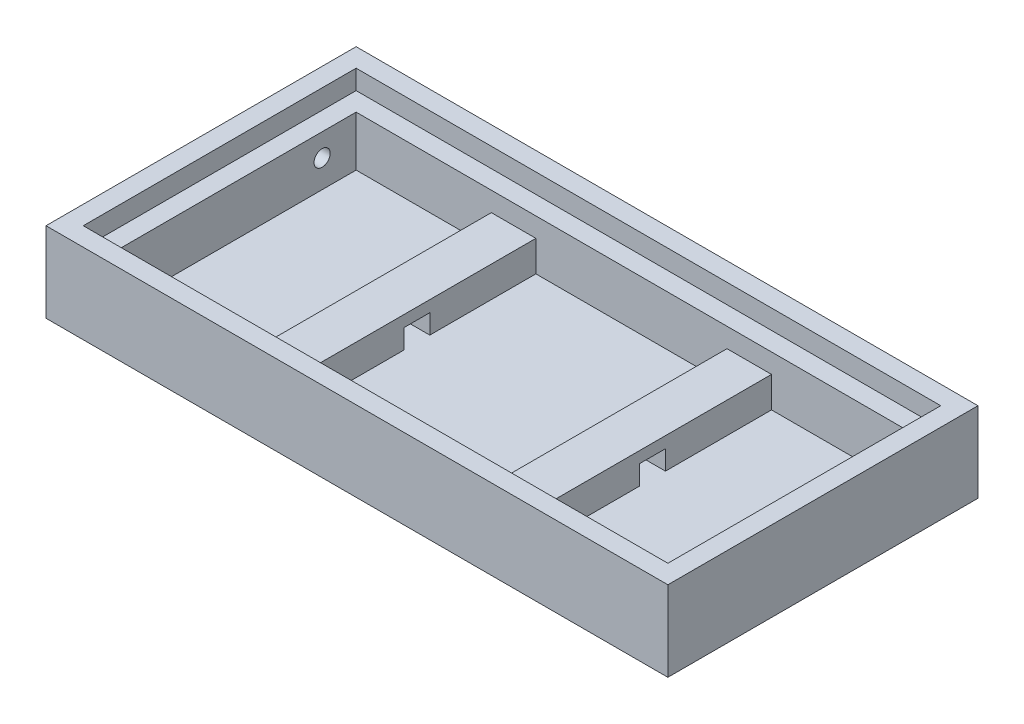
from build123d import *

# Parameters (mm, degrees)
SKETCH3_W           = 1219.2
SKETCH3_H           = 608.0125
BOSS_EXTRUDE1_DEPTH = 20.6375
SKETCH4_W           = 1219.2
SKETCH4_H           = 608.0125
SKETCH4_W_2         = 1146.175
SKETCH4_H_2         = 534.9875
BOSS_EXTRUDE2_DEPTH = 136.525
SKETCH5_W           = 1146.175
SKETCH5_H           = 534.9875
SKETCH5_W_2         = 1073.15
SKETCH5_H_2         = 461.9625
BOSS_EXTRUDE3_DEPTH = 98.425
SKETCH6_W           = 87.3125
SKETCH6_H           = 461.9625
BOSS_EXTRUDE4_DEPTH = 60.325
SKETCH7_W           = 50.8
SKETCH7_H           = 38.1
CUT_EXTRUDE1_DEPTH  = 549.275
SKETCH8_R           = 15.875
CUT_EXTRUDE2_DEPTH  = 73.025


with BuildPart() as part:
    # Sketch3 → Boss-Extrude1 (new body)
    with BuildSketch(Plane(origin=(0, 0, 0), x_dir=(1, 0, 0), z_dir=(0, 1, 0))):
        with Locations((609.6, 304.00625)):
            Rectangle(SKETCH3_W, SKETCH3_H)
    extrude(amount=BOSS_EXTRUDE1_DEPTH)

    # Sketch4 → Boss-Extrude2 (add)
    with BuildSketch(Plane(origin=(0, 20.6375, 0), x_dir=(1, 0, 0), z_dir=(0, 1, 0))):
        with Locations((609.6, 304.00625)):
            Rectangle(SKETCH4_W, SKETCH4_H)
        with Locations((609.6, 304.00625)):
            Rectangle(SKETCH4_W_2, SKETCH4_H_2, mode=Mode.SUBTRACT)
    extrude(amount=BOSS_EXTRUDE2_DEPTH)

    # Sketch5 → Boss-Extrude3 (add)
    with BuildSketch(Plane(origin=(0, 20.6375, 0), x_dir=(1, 0, 0), z_dir=(0, 1, 0))):
        with Locations((609.6, 304.00625)):
            Rectangle(SKETCH5_W, SKETCH5_H)
        with Locations((609.6, 304.00625)):
            Rectangle(SKETCH5_W_2, SKETCH5_H_2, mode=Mode.SUBTRACT)
    extrude(amount=BOSS_EXTRUDE3_DEPTH)

    # Sketch6 → Boss-Extrude4 (add)
    with BuildSketch(Plane(origin=(0, 20.6375, 0), x_dir=(1, 0, 0), z_dir=(0, 1, 0))):
        with Locations((843.75625, 304.00625)):
            Rectangle(SKETCH6_W, SKETCH6_H)
        with Locations((381.79375, 304.00625)):
            Rectangle(SKETCH6_W, SKETCH6_H)
    extrude(amount=BOSS_EXTRUDE4_DEPTH)

    # Sketch7 → Cut-Extrude1 (cut)
    with BuildSketch(Plane(origin=(887.4125, 0, 0), x_dir=(0, 0, -1), z_dir=(1, 0, 0))):
        with Locations((301.625, 39.6875)):
            Rectangle(SKETCH7_W, SKETCH7_H)
    extrude(amount=-CUT_EXTRUDE1_DEPTH, mode=Mode.SUBTRACT)

    # Sketch8 → Cut-Extrude2 (cut)
    with BuildSketch(Plane(origin=(73.025, 0, 0), x_dir=(0, 0, -1), z_dir=(1, 0, 0))):
        with Locations((468.3125, 74.6125)):
            Circle(SKETCH8_R)
    extrude(amount=-CUT_EXTRUDE2_DEPTH, mode=Mode.SUBTRACT)


solid = part.part
